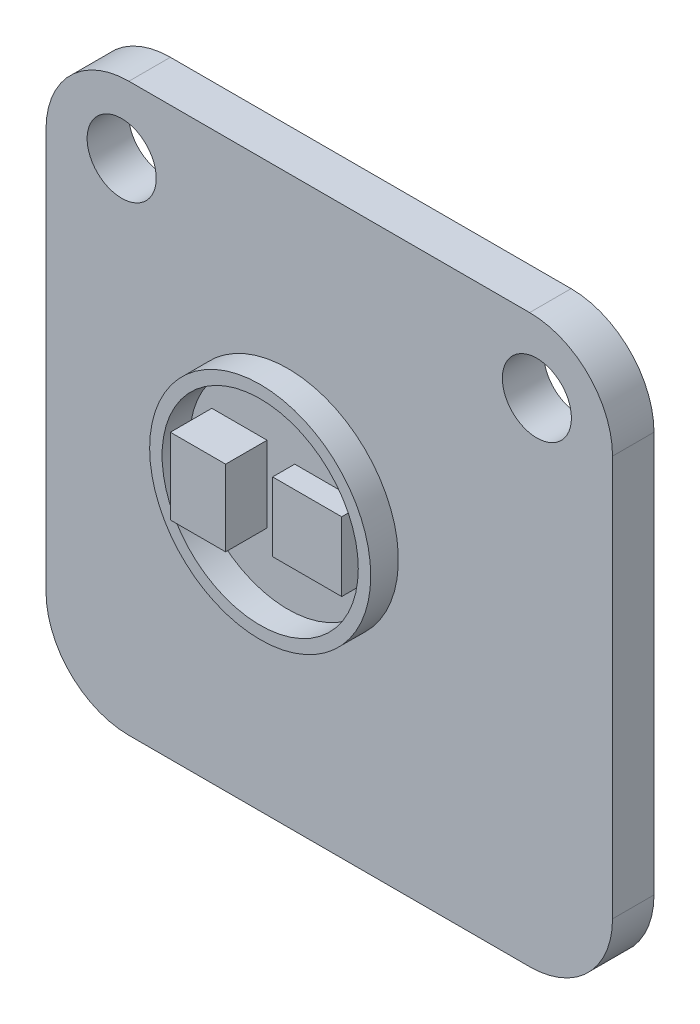
from build123d import *

# Parameters (mm, degrees)
SKETCH1_W           = 20.5
SKETCH1_H           = 20.5
BOSS_EXTRUDE1_DEPTH = 1.5
FILLET1_R           = 3
SKETCH9_R           = 1.25
CUT_EXTRUDE1_DEPTH  = 4.5
SKETCH10_W          = 2.5
SKETCH10_H          = 2.5
BOSS_EXTRUDE2_DEPTH = 0.8
SKETCH11_W          = 2
SKETCH11_H          = 2.75
BOSS_EXTRUDE3_DEPTH = 1.5
SKETCH12_R          = 4
SKETCH12_R_2        = 3.55
BOSS_EXTRUDE4_DEPTH = 1


with BuildPart() as part:
    # Sketch1 → Boss-Extrude1 (new body)
    with BuildSketch(Plane.XY):
        with Locations((10.25, 10.25)):
            Rectangle(SKETCH1_W, SKETCH1_H)
    extrude(amount=BOSS_EXTRUDE1_DEPTH)

    # Fillet1
    fillet1_edges = [part.edges().sort_by_distance(p)[0] for p in [
        (0, 20.5, 0.75),
        (20.5, 20.5, 0.75),
        (20.5, 0, 0.75),
        (0, 0, 0.75),
    ]]
    fillet(fillet1_edges, radius=FILLET1_R)

    # Sketch9 → Cut-Extrude1 (cut)
    with BuildSketch(Plane.XY.offset(1.5)):
        with Locations((17.762103221, 17.95)):
            Circle(SKETCH9_R)
        with Locations((2.737896779, 17.95)):
            Circle(SKETCH9_R)
    extrude(amount=-CUT_EXTRUDE1_DEPTH, mode=Mode.SUBTRACT)

    # Sketch10 → Boss-Extrude2 (add)
    with BuildSketch(Plane.XY.offset(1.5)):
        with Locations((10.25, 10.25)):
            Rectangle(SKETCH10_W, SKETCH10_H)
    extrude(amount=BOSS_EXTRUDE2_DEPTH)

    # Sketch11 → Boss-Extrude3 (add)
    with BuildSketch(Plane.XY.offset(1.5)):
        with Locations((7, 10.375)):
            Rectangle(SKETCH11_W, SKETCH11_H)
    extrude(amount=BOSS_EXTRUDE3_DEPTH)

    # Sketch12 → Boss-Extrude4 (add)
    with BuildSketch(Plane.XY.offset(1.5)):
        with Locations((8.75, 10.375)):
            Circle(SKETCH12_R)
        with Locations((8.75, 10.375)):
            Circle(SKETCH12_R_2, mode=Mode.SUBTRACT)
    extrude(amount=BOSS_EXTRUDE4_DEPTH)


solid = part.part
